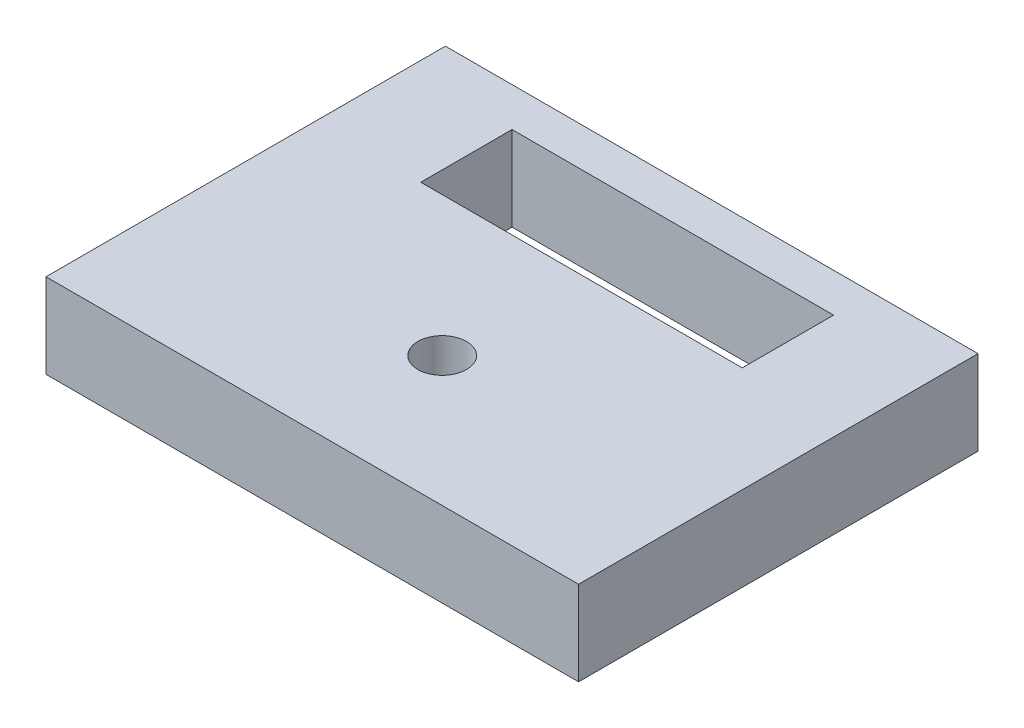
from build123d import *

# Parameters (mm, degrees)
SKETCH1_W             = 40
SKETCH1_H             = 30
BOSS_EXTRUDE1_DEPTH   = 6.35
SKETCH2_W             = 24.148
SKETCH2_H             = 6.858
CUT_EXTRUDE1_DEPTH    = 7.35
F_6_CLEARANCE_HOLE1_D = 3.6576


with BuildPart() as part:
    # Sketch1 → Boss-Extrude1 (new body)
    with BuildSketch(Plane(origin=(0, 0, 0), x_dir=(1, 0, 0), z_dir=(0, 1, 0))):
        Rectangle(SKETCH1_W, SKETCH1_H)
    extrude(amount=BOSS_EXTRUDE1_DEPTH)

    # Sketch2 → Cut-Extrude1 (cut, through all)
    with BuildSketch(Plane(origin=(0, 6.35, 0), x_dir=(1, 0, 0), z_dir=(0, 1, 0))):
        with Locations((0, 8.65)):
            Rectangle(SKETCH2_W, SKETCH2_H)
    extrude(amount=-CUT_EXTRUDE1_DEPTH, mode=Mode.SUBTRACT)

    # #6 Clearance Hole1 (through all)
    with Locations(Plane(origin=(0, 6.35, 0), x_dir=(1, 0, 0), z_dir=(0, 1, 0))):
        with Locations((0, -5.2438)):
            Hole(F_6_CLEARANCE_HOLE1_D / 2)


solid = part.part
